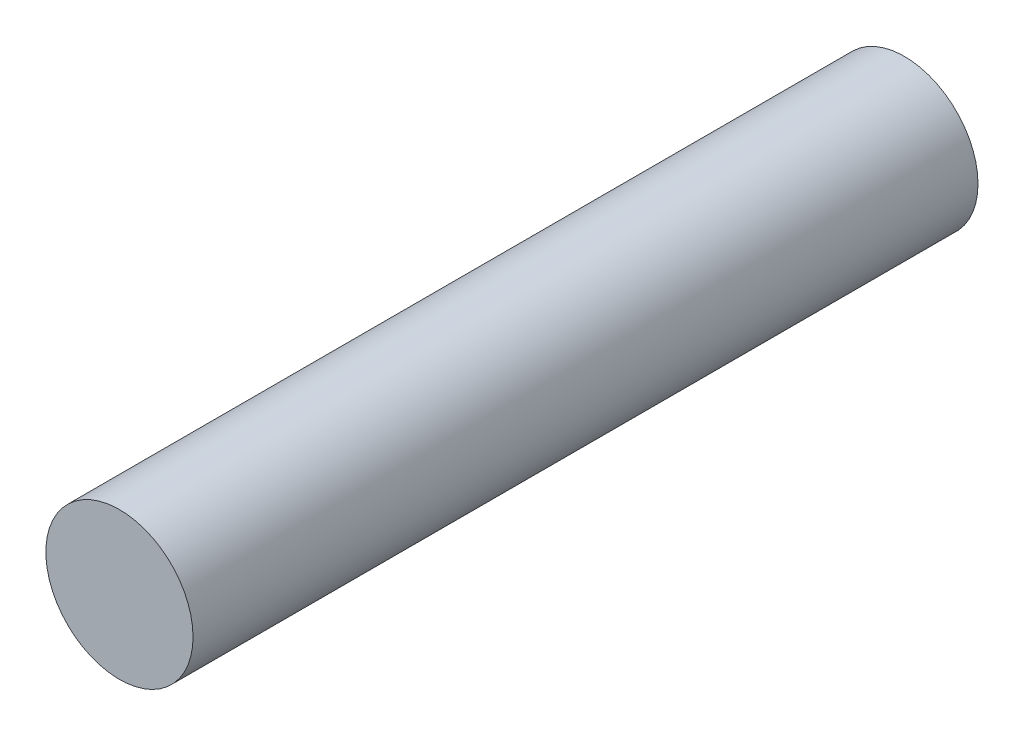
from build123d import *

# Parameters (mm, degrees)
SKETCH3_R           = 4.7625
BOSS_EXTRUDE1_DEPTH = 50.8


with BuildPart() as part:
    # Sketch3 → Boss-Extrude1 (new body)
    with BuildSketch(Plane.XY):
        Circle(SKETCH3_R)
    extrude(amount=BOSS_EXTRUDE1_DEPTH)


solid = part.part
